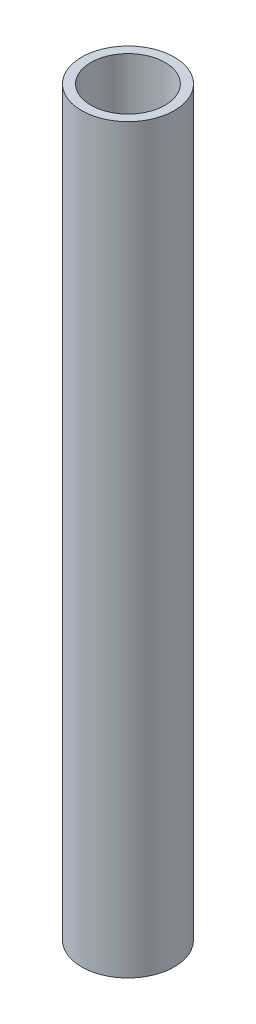
from build123d import *

# Parameters (mm, degrees)
SKETCH1_R           = 5
SKETCH1_R_2         = 4
BOSS_EXTRUDE1_DEPTH = 40


with BuildPart() as part:
    # Sketch1 → Boss-Extrude1 (new body, symmetric)
    with BuildSketch(Plane(origin=(0, 0, 0), x_dir=(1, 0, 0), z_dir=(0, 1, 0))):
        Circle(SKETCH1_R)
        Circle(SKETCH1_R_2, mode=Mode.SUBTRACT)
    extrude(amount=BOSS_EXTRUDE1_DEPTH, both=True)


solid = part.part
